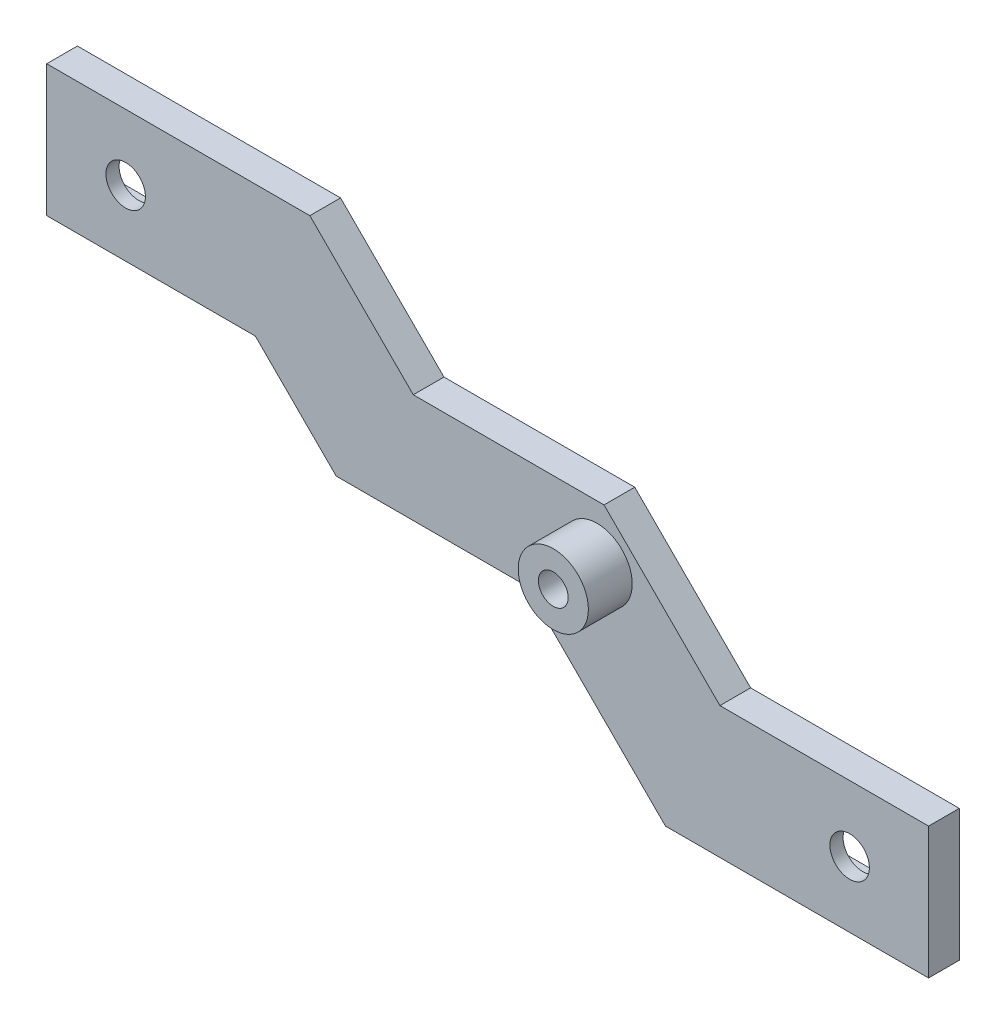
from build123d import *

# Parameters (mm, degrees)
SKETCH_1_W          = 100.539230484
SKETCH_1_H          = 40
SKETCH_1_W_2        = 17
SKETCH_1_H_2        = 7
EXTRUDE_1_DEPTH     = 2
SKETCH_2_W          = 100.539230484
SKETCH_2_H          = 40
SKETCH_2_R          = 2.25
EXTRUDE_2_DEPTH     = 1.5
SKETCH_3_W          = 184.808915215
SKETCH_3_H          = 94.825170589
CUT_EXTRUDE_1_DEPTH = 31.5
SKETCH_5_R          = 4
EXTRUDE_4_DEPTH     = 5
SKETCH_6_R          = 1.7
CUT_EXTRUDE_2_DEPTH = 10


with BuildPart() as part:
    # Эскиз1 → Бобышка-Вытянуть1 (new body)
    with BuildSketch(Plane.XY):
        with Locations((62.5, 12.5)):
            Rectangle(SKETCH_1_W, SKETCH_1_H)
        with Locations((24.230384758, 25)):
            Rectangle(SKETCH_1_W_2, SKETCH_1_H_2, mode=Mode.SUBTRACT)
        with Locations((100.769615242, 0)):
            Rectangle(SKETCH_1_W_2, SKETCH_1_H_2, mode=Mode.SUBTRACT)
    extrude(amount=EXTRUDE_1_DEPTH)

    # Эскиз2 → Бобышка-Вытянуть2 (add)
    with BuildSketch(Plane.XY.offset(2)):
        with Locations((62.5, 12.5)):
            Rectangle(SKETCH_2_W, SKETCH_2_H)
        with Locations((21.230384758, 25)):
            Circle(SKETCH_2_R, mode=Mode.SUBTRACT)
        with Locations((103.769615242, 0)):
            Circle(SKETCH_2_R, mode=Mode.SUBTRACT)
    extrude(amount=EXTRUDE_2_DEPTH)

    # Эскиз3 → Вырез-Вытянуть1 (cut)
    with BuildSketch(Plane.XY.offset(3.5)):
        with Locations((81.231416835, 7.831688581)):
            Rectangle(SKETCH_3_W, SKETCH_3_H)
        Polygon((12.230384758, 32.5), (42.230384758, 32.5), (54.020384758, 20.71), (75.769615242, 20.71), (88.979615242, 7.5), (112.769615242, 7.5), (112.769615242, -7.5), (82.769615242, -7.5), (66.982818678, 8.286796564), (45.230384758, 8.286796564), (36.017181322, 17.5), (12.230384758, 17.5), align=None, mode=Mode.SUBTRACT)
    extrude(amount=-CUT_EXTRUDE_1_DEPTH, mode=Mode.SUBTRACT)

    # Эскиз5 → Бобышка-Вытянуть4 (add)
    with BuildSketch(Plane.XY.offset(3.5)):
        with Locations((74.982818678, 14.5)):
            Circle(SKETCH_5_R)
    extrude(amount=EXTRUDE_4_DEPTH)

    # Эскиз6 → Вырез-Вытянуть2 (cut)
    with BuildSketch(Plane.XY.offset(8.5)):
        with Locations((74.982818678, 14.5)):
            Circle(SKETCH_6_R)
    extrude(amount=-CUT_EXTRUDE_2_DEPTH, mode=Mode.SUBTRACT)


solid = part.part
